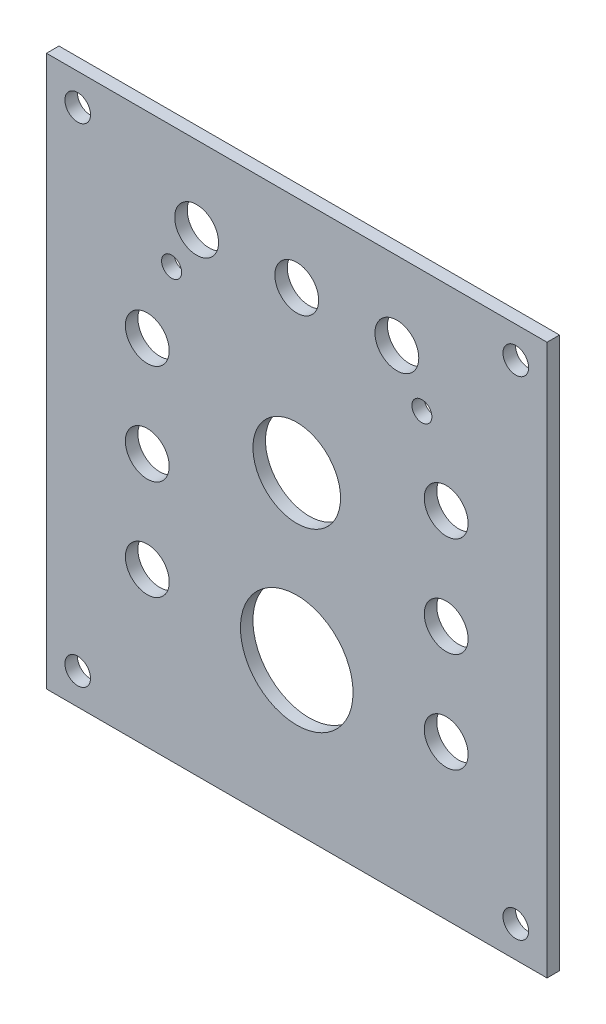
from build123d import *

# Parameters (mm, degrees)
SKETCH1_W           = 127
SKETCH1_H           = 139.7
SKETCH1_R           = 3.2512
SKETCH1_R_2         = 5.5626
SKETCH1_R_3         = 11.1125
SKETCH1_R_4         = 14.2875
SKETCH1_R_5         = 2.54
BOSS_EXTRUDE1_DEPTH = 3.175


with BuildPart() as part:
    # Sketch1 → Boss-Extrude1 (new body)
    with BuildSketch(Plane(origin=(0, 0, -3.175), x_dir=(-1, 0, 0), z_dir=(0, 0, -1))):
        with Locations((0, 31.75)):
            Rectangle(SKETCH1_W, SKETCH1_H)
        with Locations((55.5752, -30.1752)):
            Circle(SKETCH1_R, mode=Mode.SUBTRACT)
        with Locations((0, 81.8388)):
            Circle(SKETCH1_R_2, mode=Mode.SUBTRACT)
        with Locations((37.915221739, 51.777178589)):
            Circle(SKETCH1_R_2, mode=Mode.SUBTRACT)
        with Locations((-37.915221739, 0.977178589)):
            Circle(SKETCH1_R_2, mode=Mode.SUBTRACT)
        with Locations((-25.4, 81.8388)):
            Circle(SKETCH1_R_2, mode=Mode.SUBTRACT)
        with Locations((0, 41.148)):
            Circle(SKETCH1_R_3, mode=Mode.SUBTRACT)
        with Locations((-55.5752, 93.6752)):
            Circle(SKETCH1_R, mode=Mode.SUBTRACT)
        with Locations((-55.5752, -30.1752)):
            Circle(SKETCH1_R, mode=Mode.SUBTRACT)
        with Locations((55.5752, 93.6752)):
            Circle(SKETCH1_R, mode=Mode.SUBTRACT)
        Circle(SKETCH1_R_4, mode=Mode.SUBTRACT)
        with Locations((25.4, 81.8388)):
            Circle(SKETCH1_R_2, mode=Mode.SUBTRACT)
        with Locations((-37.915221739, 51.777178589)):
            Circle(SKETCH1_R_2, mode=Mode.SUBTRACT)
        with Locations((37.915221739, 0.977178589)):
            Circle(SKETCH1_R_2, mode=Mode.SUBTRACT)
        with Locations((37.915221739, 26.377178589)):
            Circle(SKETCH1_R_2, mode=Mode.SUBTRACT)
        with Locations((-37.915221739, 26.377178589)):
            Circle(SKETCH1_R_2, mode=Mode.SUBTRACT)
        with Locations((31.75, 70.58025)):
            Circle(SKETCH1_R_5, mode=Mode.SUBTRACT)
        with Locations((-31.75, 70.58025)):
            Circle(SKETCH1_R_5, mode=Mode.SUBTRACT)
    extrude(amount=-BOSS_EXTRUDE1_DEPTH)


solid = part.part
